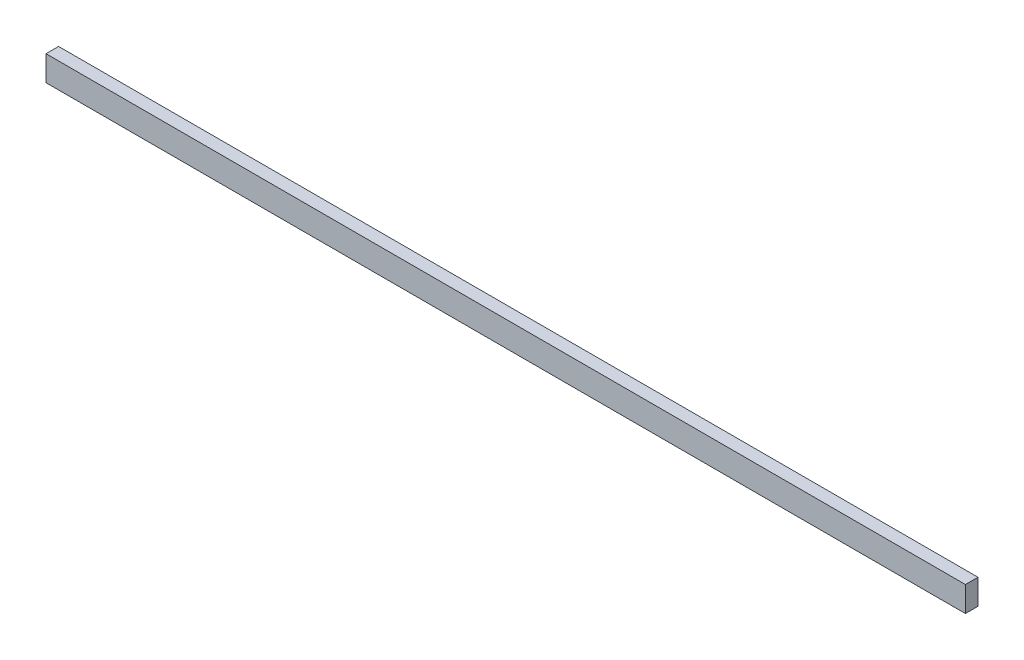
from build123d import *

# Parameters (mm, degrees)
ESQUISSE1_W        = 1096
ESQUISSE1_H        = 30
BOSS_EXTRU_1_DEPTH = 15


with BuildPart() as part:
    # Esquisse1 → Boss.-Extru.1 (new body)
    with BuildSketch(Plane.XY):
        Rectangle(ESQUISSE1_W, ESQUISSE1_H)
    extrude(amount=BOSS_EXTRU_1_DEPTH)


solid = part.part
